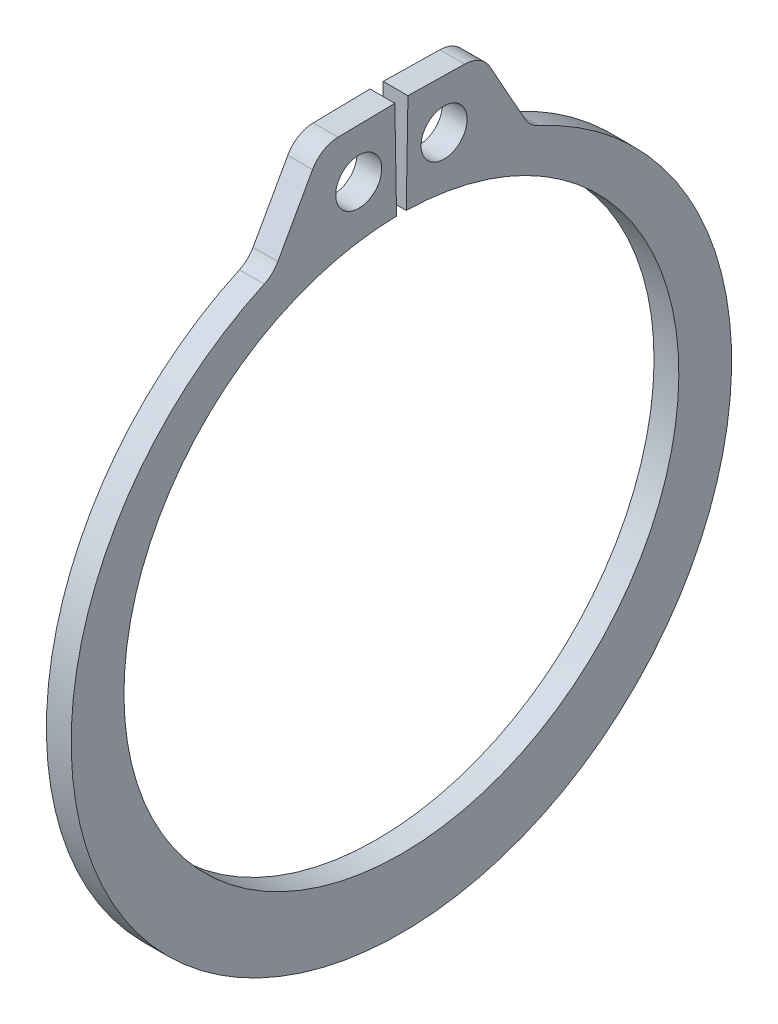
from build123d import *

# Parameters (mm, degrees)
SKETCH1_R      = 0.9906
EXTRUDE1_DEPTH = 0.5334
FILLET1_R      = 1.2827


with BuildPart() as part:
    # Sketch1 → Extrude1 (new body, symmetric)
    with BuildSketch(Plane(origin=(0, 0, 0), x_dir=(0, 0, -1), z_dir=(1, 0, 0))):
        with BuildLine():
            Line((-0.208346828, 11.936181785), (-0.282376446, 16.177335738))
            Line((-0.282376446, 16.177335738), (-3.463241911, 16.121813525))
            Line((-3.463241911, 16.121813525), (-5.525332907, 12.414975524))
            ThreePointArc((-5.525332907, 12.414975524), (0, -14.8844), (5.525332907, 12.414975524))
            Line((5.525332907, 12.414975524), (3.463241911, 16.121813525))
            Line((3.463241911, 16.121813525), (0.282376446, 16.177335738))
            Line((0.282376446, 16.177335738), (0.208346828, 11.936181785))
            ThreePointArc((0.208346828, 11.936181785), (0, -11.938), (-0.208346828, 11.936181785))
        make_face()
        with Locations((-1.835794369, 14.028997655)):
            Circle(SKETCH1_R, mode=Mode.SUBTRACT)
        with Locations((1.835794369, 14.028997655)):
            Circle(SKETCH1_R, mode=Mode.SUBTRACT)
    extrude(amount=EXTRUDE1_DEPTH, both=True)

    # Fillet1
    fillet1_edges = [part.edges().sort_by_distance(p)[0] for p in [
        (0, 16.121813525, -3.463241911),
        (0, 12.414975524, -5.525332907),
        (0, 12.414975524, 5.525332907),
        (0, 16.121813525, 3.463241911),
    ]]
    fillet(fillet1_edges, radius=FILLET1_R)


solid = part.part
